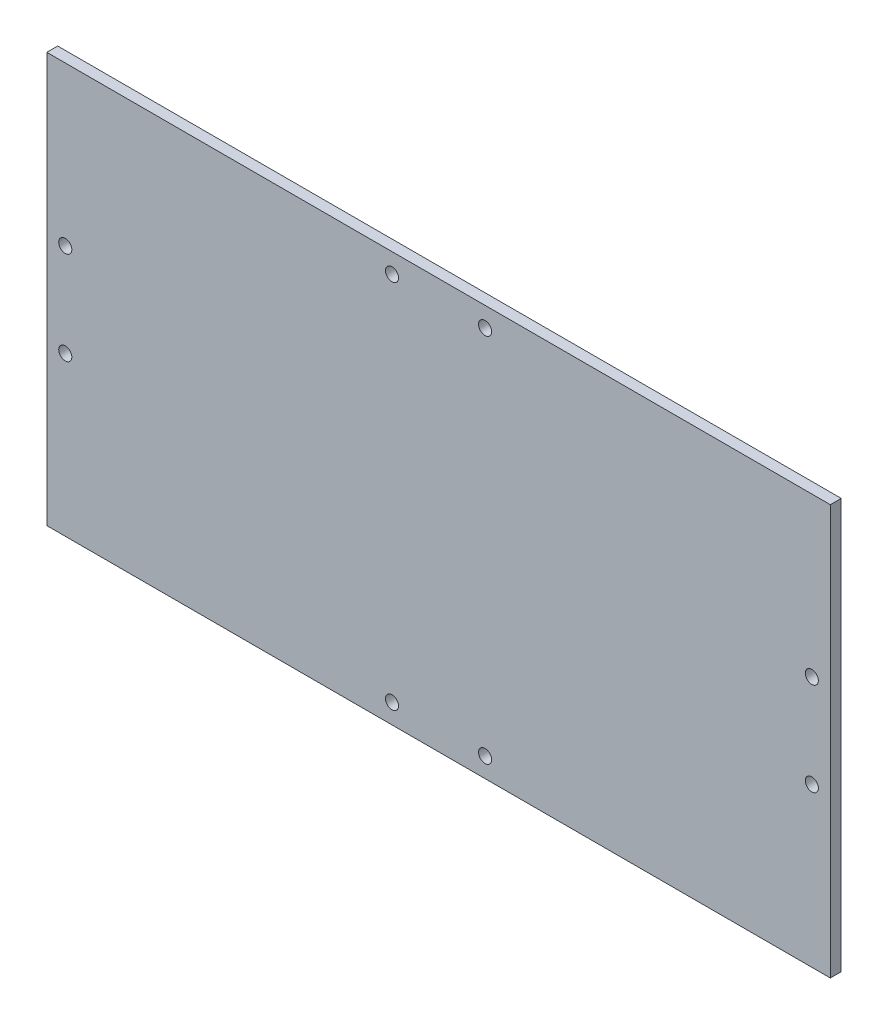
from build123d import *

# Parameters (mm, degrees)
SKETCH1_W           = 228.1936
SKETCH1_H           = 119.38
SKETCH1_R           = 1.905
BOSS_EXTRUDE1_DEPTH = 3.175


with BuildPart() as part:
    # Sketch1 → Boss-Extrude1 (new body)
    with BuildSketch(Plane.XY):
        Rectangle(SKETCH1_W, SKETCH1_H)
        with Locations((-108.712, 13.5509)):
            Circle(SKETCH1_R, mode=Mode.SUBTRACT)
        with Locations((-108.712, -13.5509)):
            Circle(SKETCH1_R, mode=Mode.SUBTRACT)
        with Locations((108.712, -13.5509)):
            Circle(SKETCH1_R, mode=Mode.SUBTRACT)
        with Locations((108.712, 13.5509)):
            Circle(SKETCH1_R, mode=Mode.SUBTRACT)
        with Locations((-13.5509, 53.975)):
            Circle(SKETCH1_R, mode=Mode.SUBTRACT)
        with Locations((13.5509, 53.975)):
            Circle(SKETCH1_R, mode=Mode.SUBTRACT)
        with Locations((13.5509, -53.975)):
            Circle(SKETCH1_R, mode=Mode.SUBTRACT)
        with Locations((-13.5509, -53.975)):
            Circle(SKETCH1_R, mode=Mode.SUBTRACT)
    extrude(amount=BOSS_EXTRUDE1_DEPTH)


solid = part.part
